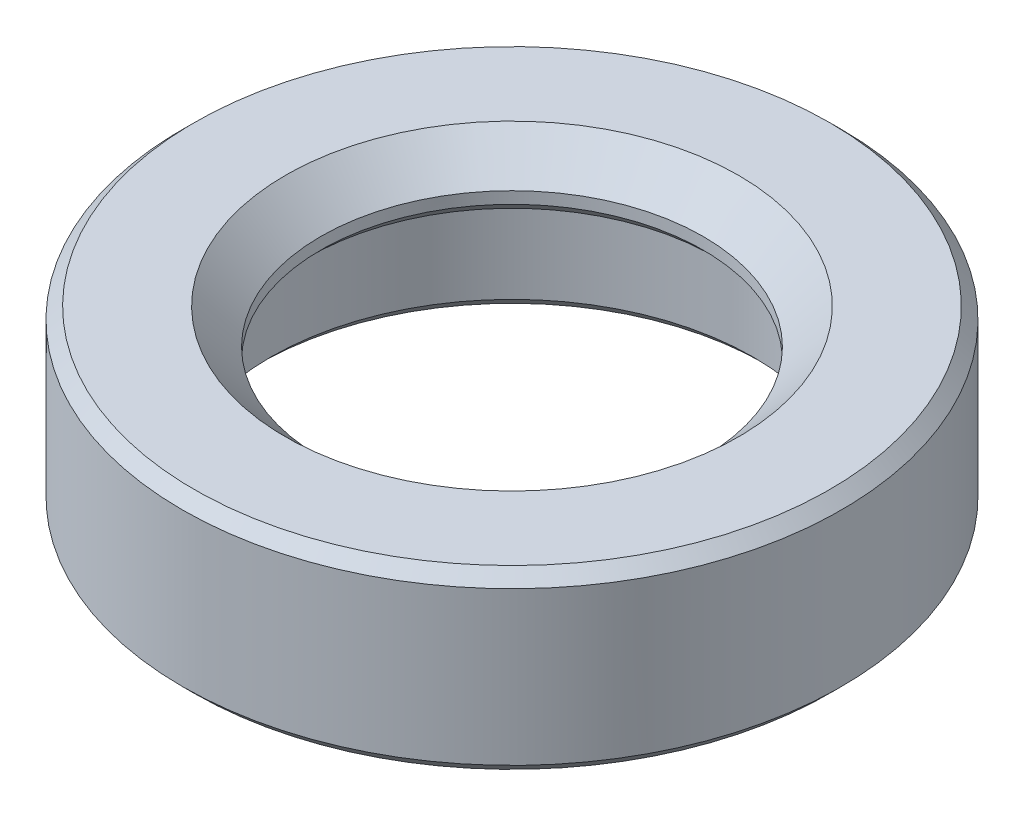
from build123d import *

# Parameters (mm, degrees)
FASE1_SIZE = 0.2
FASE2_SIZE = 0.6


with BuildPart() as part:
    # Skizze1 → Rotation1 (revolve)
    with BuildSketch(Plane(origin=(0, 0, 0), x_dir=(0, 0, -1), z_dir=(1, 0, 0))):
        Polygon((4.1, -1.5), (4.1, 0.5), (3.25, 0.5), (3.25, 1.5), (5.6, 1.5), (5.6, -1.5), align=None)
    revolve(axis=Axis((0, 14.193037975, 0), (0, -1, 0)))

    # Fase1
    fase1_edges = [part.edges().sort_by_distance(p)[0] for p in [
        (0, 0.5, 3.25),
        (0, -1.5, 4.1),
        (0, -1.5, 5.6),
        (0, 1.5, 5.6),
    ]]
    chamfer(fase1_edges, length=FASE1_SIZE)

    # Fase2
    fase2_edges = [part.edges().sort_by_distance(p)[0] for p in [
        (0, 1.5, 3.25),
    ]]
    chamfer(fase2_edges, length=FASE2_SIZE)


solid = part.part
